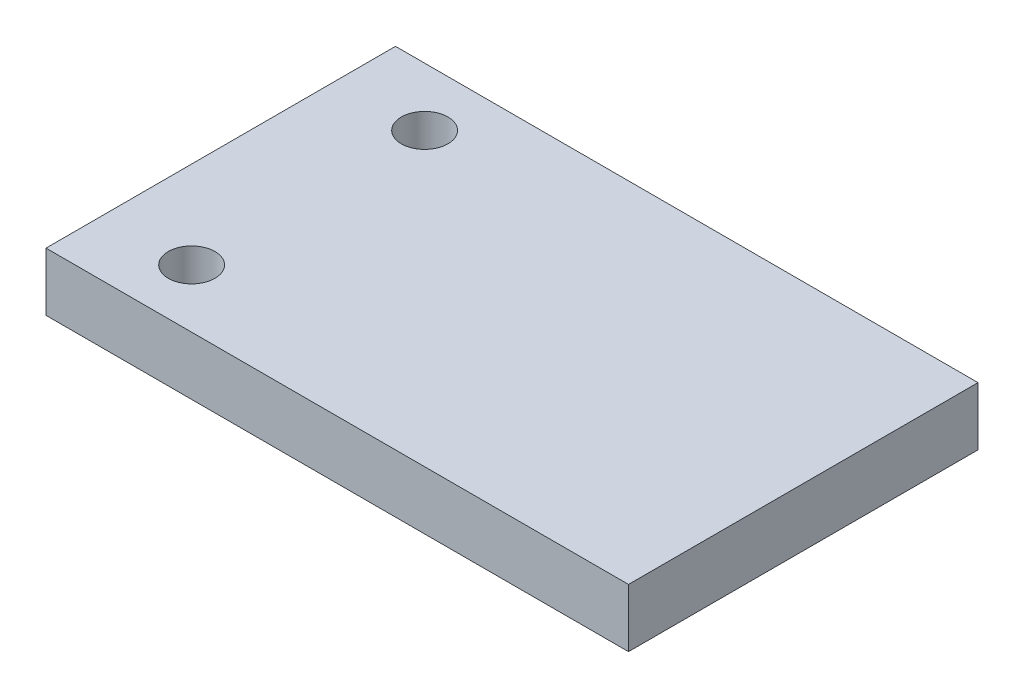
from build123d import *

# Parameters (mm, degrees)
SKETCH1_W           = 50
SKETCH1_H           = 30
BOSS_EXTRUDE1_DEPTH = 5
SKETCH2_R           = 2
CUT_EXTRUDE1_DEPTH  = 5


with BuildPart() as part:
    # Sketch1 → Boss-Extrude1 (new body)
    with BuildSketch(Plane(origin=(0, 0, 0), x_dir=(1, 0, 0), z_dir=(0, 1, 0))):
        Rectangle(SKETCH1_W, SKETCH1_H)
    extrude(amount=BOSS_EXTRUDE1_DEPTH)

    # Sketch2 → Cut-Extrude1 (cut)
    with BuildSketch(Plane(origin=(0, 5, 0), x_dir=(1, 0, 0), z_dir=(0, 1, 0))):
        with Locations((-17.5, 10)):
            Circle(SKETCH2_R)
        with Locations((-17.5, -10)):
            Circle(SKETCH2_R)
    extrude(amount=-CUT_EXTRUDE1_DEPTH, mode=Mode.SUBTRACT)


solid = part.part
